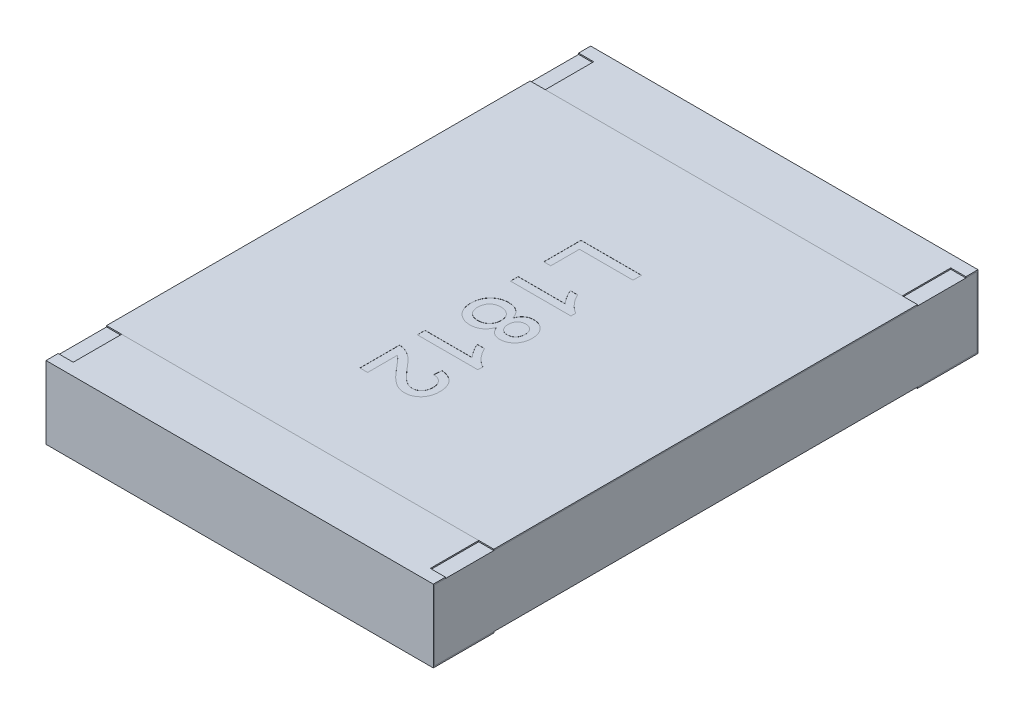
from build123d import *

# Parameters (mm, degrees)
BOSS_EXTRUDE2_DEPTH   = 1.6
BOSS_EXTRUDE2_2_DEPTH = 1.6
BOSS_EXTRUDE3_START   = -1.6
SKETCH5_W             = 4.48
SKETCH5_H             = 0.58
BOSS_EXTRUDE3_DEPTH   = 3.2
SKETCH6_W             = 0.125
SKETCH6_H             = 0.4
CUT_EXTRUDE1_DEPTH    = 0.01
SKETCH7_W             = 3.2
SKETCH7_H             = 3.5
BOSS_EXTRUDE4_DEPTH   = 0.01
TEXT1812_DEPTH        = 0.001


with BuildPart() as part:
    # Sketch4 → Boss-Extrude2 (new body, symmetric)
    with BuildSketch(Plane(origin=(0, 0, 0), x_dir=(0, 0, -1), z_dir=(1, 0, 0))):
        Polygon((-2.25, 0.3), (-2.25, -0.3), (-1.75, -0.3), (-1.75, -0.29), (-2.24, -0.29), (-2.24, 0.29), (-1.75, 0.29), (-1.75, 0.3), align=None)
    extrude(amount=BOSS_EXTRUDE2_DEPTH, both=True)


with BuildPart() as body_2:
    # Sketch4 → Boss-Extrude2 2 (new body, symmetric)
    with BuildSketch(Plane(origin=(0, 0, 0), x_dir=(0, 0, -1), z_dir=(1, 0, 0))):
        Polygon((1.75, 0.3), (2.25, 0.3), (2.25, -0.3), (1.75, -0.3), (1.75, -0.29), (2.24, -0.29), (2.24, 0.29), (1.75, 0.29), align=None)
    extrude(amount=BOSS_EXTRUDE2_2_DEPTH, both=True)


with BuildPart() as body_3:
    # Sketch5 → Boss-Extrude3 (new body)
    with BuildSketch(Plane(origin=(0, 0, 0), x_dir=(0, 0, -1), z_dir=(1, 0, 0)).offset(BOSS_EXTRUDE3_START)):
        Rectangle(SKETCH5_W, SKETCH5_H)
    extrude(amount=BOSS_EXTRUDE3_DEPTH)


with BuildPart() as cut_extrude1_tool:
    # Sketch6 → Cut-Extrude1 (new body)
    with BuildSketch(Plane(origin=(0, 0.3, 0), x_dir=(1, 0, 0), z_dir=(0, 1, 0))):
        with Locations((-1.5375, 1.95)):
            Rectangle(SKETCH6_W, SKETCH6_H)
        with Locations((1.5375, 1.95)):
            Rectangle(SKETCH6_W, SKETCH6_H)
        with Locations((1.5375, -1.95)):
            Rectangle(SKETCH6_W, SKETCH6_H)
        with Locations((-1.5375, -1.95)):
            Rectangle(SKETCH6_W, SKETCH6_H)
    extrude(amount=-CUT_EXTRUDE1_DEPTH)


with BuildPart() as part_1:
    add(part.part)

    # Cut-Extrude1: cut by cut_extrude1_tool
    add(cut_extrude1_tool.part, mode=Mode.SUBTRACT)


with BuildPart() as body_2_1:
    add(body_2.part)

    # Cut-Extrude1: cut by cut_extrude1_tool
    add(cut_extrude1_tool.part, mode=Mode.SUBTRACT)


with BuildPart() as body_4:
    # Sketch7 → Boss-Extrude4 (new body)
    with BuildSketch(Plane(origin=(0, 0.29, 0), x_dir=(1, 0, 0), z_dir=(0, 1, 0))):
        Rectangle(SKETCH7_W, SKETCH7_H)
    extrude(amount=BOSS_EXTRUDE4_DEPTH)

    # Sketch14 → TEXT1812 (cut)
    with BuildSketch(Plane(origin=(0, 0.3, 0), x_dir=(1, 0, 0), z_dir=(0, 1, 0))):
        Polygon((-0.25, 0.820138052), (0.25, 0.820138052), (0.25, 0.749625231), (-0.192307692, 0.749625231), (-0.192307692, 0.512445744), (-0.25, 0.512445744), align=None)
        with BuildLine():
            Line((-0.25, 0.236804718), (-0.25, 0.300907282))
            Line((-0.25, 0.300907282), (0.139623397, 0.300907282))
            add(Edge.make_bspline(
                [(0.139623397, 0.300907282), (0.136064182, 0.304598525), (0.128666742, 0.312270369), (0.118190939, 0.32523447), (0.107619408, 0.339700891), (0.097315673, 0.355429648), (0.08780582, 0.371586212), (0.079128194, 0.387152151), (0.071822591, 0.401910054), (0.067824115, 0.411628505), (0.065905449, 0.416291898)],
                knots=[0, 0, 0, 0, 1.5377e-05, 3.1959e-05, 4.9949e-05, 6.9117e-05, 8.8339e-05, 0.000106181, 0.000122576, 0.0001377, 0.0001377, 0.0001377, 0.0001377], degree=3))
            Line((0.065905449, 0.416291898), (0.125, 0.416291898))
            add(Edge.make_bspline(
                [(0.125, 0.416291898), (0.129125269, 0.408281697), (0.137255931, 0.392494067), (0.151298701, 0.370189558), (0.166521642, 0.3493659), (0.182921383, 0.330367807), (0.199684862, 0.313337227), (0.216599871, 0.29898531), (0.233046379, 0.286976539), (0.244515995, 0.280951511), (0.25, 0.278070744)],
                knots=[0, 0, 0, 0, 2.702e-05, 5.3254e-05, 7.8977e-05, 0.000104333, 0.000128484, 0.000150581, 0.000170841, 0.000189403, 0.000189403, 0.000189403, 0.000189403], degree=3))
            Line((0.25, 0.278070744), (0.25, 0.236804718))
            Line((0.25, 0.236804718), (-0.25, 0.236804718))
        make_face()
        with BuildLine():
            add(Edge.make_bspline(
                [(0.024238782, -0.018403615), (0.02539818, -0.015281088), (0.027670824, -0.009160331), (0.031729797, -0.000465484), (0.035977971, 0.007684965), (0.040722444, 0.015141883), (0.045841435, 0.02194777), (0.05125653, 0.028215415), (0.057051297, 0.033819199), (0.065251162, 0.040403963), (0.076469857, 0.047168124), (0.091129194, 0.053208557), (0.107150389, 0.056621476), (0.118206708, 0.057080991), (0.123898237, 0.057317539)],
                knots=[0, 0, 0, 0, 9.988e-06, 1.9579e-05, 2.8765e-05, 3.7545e-05, 4.6059e-05, 5.4294e-05, 6.2369e-05, 7.0206e-05, 8.5803e-05, 0.000101483, 0.000117572, 0.000134642, 0.000134642, 0.000134642, 0.000134642], degree=3))
            add(Edge.make_bspline(
                [(0.123898237, 0.057317539), (0.128278386, 0.057207296), (0.136876757, 0.056990886), (0.149495643, 0.055128788), (0.161579073, 0.052127737), (0.17314744, 0.047929631), (0.184113889, 0.042438802), (0.194640222, 0.035914222), (0.204558084, 0.028059088), (0.213797595, 0.019055628), (0.22236411, 0.009184216), (0.229759149, -0.001650872), (0.236018114, -0.013274409), (0.241127177, -0.025663435), (0.245166426, -0.038834398), (0.247909652, -0.052833921), (0.249656619, -0.067604982), (0.249883757, -0.077726769), (0.25, -0.08290682)],
                knots=[0, 0, 0, 0, 1.3135e-05, 2.5784e-05, 3.8173e-05, 5.0436e-05, 6.2619e-05, 7.4903e-05, 8.7527e-05, 0.00010049, 0.000113559, 0.000126672, 0.000139758, 0.000153094, 0.000166813, 0.000181015, 0.000195837, 0.000211373, 0.000211373, 0.000211373, 0.000211373], degree=3))
            add(Edge.make_bspline(
                [(0.25, -0.08290682), (0.249882531, -0.088119853), (0.249653714, -0.098274252), (0.247930845, -0.11312416), (0.245043208, -0.127210704), (0.240946379, -0.140525591), (0.235708336, -0.153089813), (0.229270093, -0.164820809), (0.221737839, -0.175839344), (0.213021747, -0.185863787), (0.203558906, -0.194984836), (0.193421, -0.202887363), (0.18284459, -0.209665109), (0.171765423, -0.215265897), (0.160057336, -0.219409382), (0.147940915, -0.222567647), (0.135272194, -0.224399587), (0.126675148, -0.224620968), (0.122295673, -0.224733743)],
                knots=[0, 0, 0, 0, 1.5637e-05, 3.0458e-05, 4.4778e-05, 5.8718e-05, 7.2186e-05, 8.5543e-05, 9.8796e-05, 0.000112147, 0.000125324, 0.000138167, 0.000150642, 0.00016296, 0.000175317, 0.000187828, 0.000200477, 0.000213612, 0.000213612, 0.000213612, 0.000213612], degree=3))
            add(Edge.make_bspline(
                [(0.122295673, -0.224733743), (0.116799676, -0.22454979), (0.10602306, -0.224189091), (0.090480034, -0.220539131), (0.076018484, -0.214801225), (0.062720931, -0.206703486), (0.050803482, -0.196122782), (0.040306374, -0.18318584), (0.031199936, -0.167895992), (0.026621629, -0.156530493), (0.024238782, -0.150615153)],
                knots=[0, 0, 0, 0, 1.6463e-05, 3.2281e-05, 4.7607e-05, 6.2981e-05, 7.8735e-05, 9.5177e-05, 0.000112783, 0.000131893, 0.000131893, 0.000131893, 0.000131893], degree=3))
            add(Edge.make_bspline(
                [(0.024238782, -0.150615153), (0.022972264, -0.15434827), (0.020490437, -0.161663558), (0.015654785, -0.171998845), (0.010491973, -0.181728536), (0.004755578, -0.19084414), (-0.001623653, -0.199214696), (-0.008616028, -0.206897991), (-0.016120459, -0.213941507), (-0.024261073, -0.220236187), (-0.032853908, -0.225862337), (-0.041930308, -0.230661063), (-0.051322704, -0.234796875), (-0.061196276, -0.238091248), (-0.071409343, -0.240847143), (-0.082118687, -0.242577705), (-0.093157345, -0.243725752), (-0.100658015, -0.243884098), (-0.104467147, -0.243964512)],
                knots=[0, 0, 0, 0, 1.1818e-05, 2.3157e-05, 3.4181e-05, 4.4851e-05, 5.5428e-05, 6.571e-05, 7.5985e-05, 8.6264e-05, 9.6542e-05, 0.000106759, 0.000117031, 0.000127293, 0.000137958, 0.000148727, 0.0001598, 0.000171225, 0.000171225, 0.000171225, 0.000171225], degree=3))
            add(Edge.make_bspline(
                [(-0.104467147, -0.243964512), (-0.109716763, -0.243837132), (-0.120058905, -0.243586184), (-0.135239829, -0.241380953), (-0.149823668, -0.238045088), (-0.163746516, -0.233178311), (-0.177026708, -0.226971864), (-0.189596023, -0.219269027), (-0.201582432, -0.210303597), (-0.212864831, -0.200075975), (-0.222998595, -0.188571212), (-0.232020834, -0.17621777), (-0.239541591, -0.16288028), (-0.245775203, -0.148730445), (-0.25060455, -0.133692382), (-0.253986549, -0.117787644), (-0.256000272, -0.101020908), (-0.256271764, -0.089556358), (-0.256410256, -0.083708102)],
                knots=[0, 0, 0, 0, 1.5741e-05, 3.1011e-05, 4.5928e-05, 6.0562e-05, 7.5169e-05, 8.9822e-05, 0.000104705, 0.00012002, 0.000135416, 0.000150623, 0.000165829, 0.000181256, 0.000196936, 0.000213123, 0.000229969, 0.000247512, 0.000247512, 0.000247512, 0.000247512], degree=3))
            add(Edge.make_bspline(
                [(-0.256410256, -0.083708102), (-0.256268784, -0.077860427), (-0.255991451, -0.066397015), (-0.254018827, -0.049615019), (-0.250483765, -0.033732826), (-0.24564863, -0.01871507), (-0.239586942, -0.004478045), (-0.23188486, 0.008759823), (-0.22294704, 0.02119123), (-0.212624421, 0.032529782), (-0.201347774, 0.042812622), (-0.189308416, 0.051894921), (-0.176534929, 0.059518571), (-0.163096374, 0.065813945), (-0.148943574, 0.070604959), (-0.134138206, 0.073969271), (-0.118689254, 0.076178202), (-0.108147498, 0.076423201), (-0.102764423, 0.076548308)],
                knots=[0, 0, 0, 0, 1.7542e-05, 3.4388e-05, 5.0597e-05, 6.6276e-05, 8.1664e-05, 9.692e-05, 0.000112127, 0.000127515, 0.000142829, 0.000157853, 0.000172678, 0.000187375, 0.000202294, 0.000217406, 0.000232874, 0.000249015, 0.000249015, 0.000249015, 0.000249015], degree=3))
            add(Edge.make_bspline(
                [(-0.102764423, 0.076548308), (-0.098756291, 0.076461416), (-0.090891642, 0.076290919), (-0.079356793, 0.075247857), (-0.068361168, 0.073173738), (-0.057847876, 0.070487423), (-0.047749211, 0.067125146), (-0.03826149, 0.062784714), (-0.029246667, 0.057730039), (-0.020751206, 0.051949572), (-0.012849932, 0.045402835), (-0.005462304, 0.038306998), (0.001111121, 0.030415976), (0.007217111, 0.022030101), (0.012370618, 0.012776387), (0.017102053, 0.003009595), (0.021136528, -0.007441155), (0.023194341, -0.014712865), (0.024238782, -0.018403615)],
                knots=[0, 0, 0, 0, 1.2026e-05, 2.3597e-05, 3.4697e-05, 4.5556e-05, 5.6135e-05, 6.6579e-05, 7.6804e-05, 8.7111e-05, 9.7357e-05, 0.000107557, 0.000117791, 0.00012813, 0.000138628, 0.000149514, 0.000160675, 0.000172178, 0.000172178, 0.000172178, 0.000172178], degree=3))
        make_face()
        with BuildLine():
            add(Edge.make_bspline(
                [(0.123597756, -0.006785025), (0.120991462, -0.0068427), (0.115896151, -0.006955456), (0.108439177, -0.007837621), (0.101377018, -0.009481524), (0.094654968, -0.011655877), (0.088296098, -0.014507799), (0.082239417, -0.017885961), (0.07663087, -0.022036111), (0.071437279, -0.02673761), (0.066668381, -0.031954448), (0.062556899, -0.037820128), (0.059025979, -0.044223923), (0.056288833, -0.051225851), (0.053861642, -0.058646941), (0.05250548, -0.066745793), (0.051402828, -0.075331297), (0.05132298, -0.081266687), (0.051282051, -0.084309064)],
                knots=[0, 0, 0, 0, 7.818e-06, 1.5285e-05, 2.2477e-05, 2.954e-05, 3.6445e-05, 4.3353e-05, 5.0304e-05, 5.7325e-05, 6.4345e-05, 7.146e-05, 7.8766e-05, 8.6224e-05, 9.3986e-05, 0.000102138, 0.00011081, 0.00011993, 0.00011993, 0.00011993, 0.00011993], degree=3))
            add(Edge.make_bspline(
                [(0.051282051, -0.084309064), (0.051324337, -0.087284354), (0.051406793, -0.093086006), (0.052489104, -0.101477167), (0.053924062, -0.109411295), (0.05614596, -0.116780159), (0.05889885, -0.123681995), (0.06252784, -0.129897263), (0.066452675, -0.135795881), (0.072742354, -0.142613787), (0.081592622, -0.149835113), (0.093575839, -0.156123412), (0.106731646, -0.160026), (0.115891397, -0.160425911), (0.120592949, -0.160631179)],
                knots=[0, 0, 0, 0, 8.919e-06, 1.7392e-05, 2.5348e-05, 3.308e-05, 4.0446e-05, 4.7577e-05, 5.4634e-05, 6.1654e-05, 7.5326e-05, 8.8677e-05, 0.000102023, 0.000116097, 0.000116097, 0.000116097, 0.000116097], degree=3))
            add(Edge.make_bspline(
                [(0.120592949, -0.160631179), (0.125459209, -0.160384425), (0.134981221, -0.159901592), (0.148650499, -0.156001968), (0.161030782, -0.149436608), (0.170071927, -0.141936595), (0.176621705, -0.134995096), (0.180791077, -0.12905629), (0.184339581, -0.122672051), (0.187237413, -0.115818082), (0.189574544, -0.10848447), (0.191107815, -0.100651349), (0.192183151, -0.092351636), (0.192265305, -0.086649904), (0.192307692, -0.083708102)],
                knots=[0, 0, 0, 0, 1.4581e-05, 2.8532e-05, 4.2242e-05, 5.6337e-05, 6.3567e-05, 7.082e-05, 7.8039e-05, 8.5443e-05, 9.3109e-05, 0.000101085, 0.000109358, 0.000118178, 0.000118178, 0.000118178, 0.000118178], degree=3))
            add(Edge.make_bspline(
                [(0.192307692, -0.083708102), (0.192266666, -0.08076598), (0.192186687, -0.075030456), (0.191079222, -0.066676526), (0.189687591, -0.058769515), (0.187456834, -0.051380391), (0.184533253, -0.044546864), (0.181018489, -0.038196355), (0.176892408, -0.032345598), (0.170652349, -0.025355677), (0.161895936, -0.017936378), (0.150029615, -0.01150081), (0.13713766, -0.007508302), (0.12816696, -0.007029104), (0.123597756, -0.006785025)],
                knots=[0, 0, 0, 0, 8.819e-06, 1.7193e-05, 2.5247e-05, 3.2883e-05, 4.0288e-05, 4.7506e-05, 5.462e-05, 6.1715e-05, 7.5578e-05, 8.88e-05, 0.000101982, 0.000115666, 0.000115666, 0.000115666, 0.000115666], degree=3))
        make_face(mode=Mode.SUBTRACT)
        with BuildLine():
            add(Edge.make_bspline(
                [(-0.1015625, 0.012445744), (-0.105675937, 0.012335584), (-0.113913647, 0.012114975), (-0.126143608, 0.010157317), (-0.138176392, 0.006889605), (-0.149918479, 0.002498368), (-0.161048518, -0.003434237), (-0.170904356, -0.011371511), (-0.179338866, -0.021225417), (-0.1862755, -0.032650539), (-0.191829654, -0.045018672), (-0.195726919, -0.057887136), (-0.198263034, -0.070954849), (-0.198566293, -0.07979038), (-0.198717949, -0.084208903)],
                knots=[0, 0, 0, 0, 1.2334e-05, 2.4701e-05, 3.7044e-05, 4.9693e-05, 6.2243e-05, 7.471e-05, 8.7421e-05, 0.000100958, 0.000114677, 0.000127983, 0.000141224, 0.00015447, 0.00015447, 0.00015447, 0.00015447], degree=3))
            add(Edge.make_bspline(
                [(-0.198717949, -0.084208903), (-0.198656227, -0.087852609), (-0.198536319, -0.094931289), (-0.197166117, -0.105249788), (-0.195087072, -0.114972149), (-0.192236359, -0.124142905), (-0.188336404, -0.132627106), (-0.183778167, -0.140562796), (-0.178269329, -0.147869228), (-0.171981829, -0.154542736), (-0.165028627, -0.160521334), (-0.157520547, -0.165625993), (-0.149712731, -0.170134481), (-0.141294279, -0.173590018), (-0.132494834, -0.176423087), (-0.123234593, -0.178404933), (-0.113548875, -0.179646981), (-0.106941658, -0.179789254), (-0.103565705, -0.179861948)],
                knots=[0, 0, 0, 0, 1.0925e-05, 2.1224e-05, 3.1164e-05, 4.0731e-05, 4.9965e-05, 5.9121e-05, 6.8136e-05, 7.7347e-05, 8.6581e-05, 9.5583e-05, 0.000104553, 0.000113575, 0.000122825, 0.000132255, 0.000141945, 0.000152069, 0.000152069, 0.000152069, 0.000152069], degree=3))
            add(Edge.make_bspline(
                [(-0.103565705, -0.179861948), (-0.100123487, -0.179786906), (-0.093384171, -0.179639985), (-0.083485869, -0.178429083), (-0.074062616, -0.176333166), (-0.065105205, -0.173374094), (-0.05652785, -0.169819465), (-0.048457959, -0.165281241), (-0.040966071, -0.159791276), (-0.03384257, -0.153752467), (-0.027392394, -0.146923736), (-0.021830619, -0.139381316), (-0.016918505, -0.131365833), (-0.01315053, -0.122634381), (-0.010132287, -0.113379439), (-0.007939188, -0.103557009), (-0.006598604, -0.093127049), (-0.006474251, -0.085982573), (-0.006410256, -0.082305859)],
                knots=[0, 0, 0, 0, 1.0324e-05, 2.0213e-05, 2.986e-05, 3.9236e-05, 4.8482e-05, 5.7675e-05, 6.6932e-05, 7.6307e-05, 8.566e-05, 9.5035e-05, 0.00010438, 0.000113797, 0.000123489, 0.000133549, 0.000143948, 0.000154973, 0.000154973, 0.000154973, 0.000154973], degree=3))
            add(Edge.make_bspline(
                [(-0.006410256, -0.082305859), (-0.006474999, -0.078729038), (-0.006601914, -0.071717357), (-0.007948541, -0.061530473), (-0.010024387, -0.051889794), (-0.013025373, -0.042894401), (-0.0168655, -0.034452302), (-0.021594505, -0.026640586), (-0.027127484, -0.019347092), (-0.033541909, -0.012789173), (-0.04056438, -0.006918269), (-0.047939309, -0.001642959), (-0.055878465, 0.0026585), (-0.064156655, 0.006319492), (-0.072957178, 0.008966906), (-0.08208906, 0.011000506), (-0.091680221, 0.012227818), (-0.098220261, 0.01237204), (-0.1015625, 0.012445744)],
                knots=[0, 0, 0, 0, 1.0725e-05, 2.1024e-05, 3.0769e-05, 4.0271e-05, 4.9414e-05, 5.8535e-05, 6.761e-05, 7.6818e-05, 8.5987e-05, 9.5046e-05, 0.000103967, 0.000113029, 0.000122153, 0.000131485, 0.000141076, 0.0001511, 0.0001511, 0.0001511, 0.0001511], degree=3))
        make_face(mode=Mode.SUBTRACT)
        with BuildLine():
            Line((-0.25, -0.532426051), (-0.25, -0.468323487))
            Line((-0.25, -0.468323487), (0.139623397, -0.468323487))
            add(Edge.make_bspline(
                [(0.139623397, -0.468323487), (0.136064182, -0.464632244), (0.128666742, -0.4569604), (0.118190939, -0.443996299), (0.107619408, -0.429529878), (0.097315673, -0.413801121), (0.08780582, -0.397644558), (0.079128194, -0.382078618), (0.071822591, -0.367320715), (0.067824115, -0.357602264), (0.065905449, -0.352938871)],
                knots=[0, 0, 0, 0, 1.5377e-05, 3.1959e-05, 4.9949e-05, 6.9117e-05, 8.8339e-05, 0.000106181, 0.000122576, 0.0001377, 0.0001377, 0.0001377, 0.0001377], degree=3))
            Line((0.065905449, -0.352938871), (0.125, -0.352938871))
            add(Edge.make_bspline(
                [(0.125, -0.352938871), (0.129125269, -0.360949072), (0.137255931, -0.376736703), (0.151298701, -0.399041211), (0.166521642, -0.419864869), (0.182921383, -0.438862962), (0.199684862, -0.455893542), (0.216599871, -0.47024546), (0.233046379, -0.482254231), (0.244515995, -0.488279258), (0.25, -0.491160025)],
                knots=[0, 0, 0, 0, 2.702e-05, 5.3254e-05, 7.8977e-05, 0.000104333, 0.000128484, 0.000150581, 0.000170841, 0.000189403, 0.000189403, 0.000189403, 0.000189403], degree=3))
            Line((0.25, -0.491160025), (0.25, -0.532426051))
            Line((0.25, -0.532426051), (-0.25, -0.532426051))
        make_face()
        with BuildLine():
            Line((-0.185897436, -1.006785025), (-0.25, -1.006785025))
            Line((-0.25, -1.006785025), (-0.25, -0.679861948))
            add(Edge.make_bspline(
                [(-0.25, -0.679861948), (-0.246190204, -0.679855255), (-0.238583383, -0.679841892), (-0.227333376, -0.681129089), (-0.21623261, -0.683145096), (-0.209114131, -0.685424596), (-0.205528846, -0.686572685)],
                knots=[0, 0, 0, 0, 1.142e-05, 2.2802e-05, 3.392e-05, 4.5202e-05, 4.5202e-05, 4.5202e-05, 4.5202e-05], degree=3))
            add(Edge.make_bspline(
                [(-0.205528846, -0.686572685), (-0.199672194, -0.688696046), (-0.187747085, -0.693019559), (-0.170501435, -0.701745549), (-0.153461868, -0.712179782), (-0.139489569, -0.72216557), (-0.128408004, -0.731362493), (-0.11963342, -0.738946588), (-0.110764129, -0.747489919), (-0.101641984, -0.756836742), (-0.092266458, -0.766930336), (-0.082593861, -0.777770307), (-0.07280804, -0.789488773), (-0.066321448, -0.797669318), (-0.063000801, -0.801857141)],
                knots=[0, 0, 0, 0, 1.8675e-05, 3.8026e-05, 5.7849e-05, 7.8586e-05, 8.9474e-05, 0.000101045, 0.000113371, 0.000126404, 0.000140223, 0.000154696, 0.000169983, 0.000186016, 0.000186016, 0.000186016, 0.000186016], degree=3))
            add(Edge.make_bspline(
                [(-0.063000801, -0.801857141), (-0.057585784, -0.808290694), (-0.047158825, -0.820678908), (-0.031686185, -0.838173008), (-0.017318962, -0.85415102), (-0.003805341, -0.868358514), (0.008723604, -0.880911691), (0.020239487, -0.891840027), (0.03070637, -0.901237552), (0.040503108, -0.908989541), (0.049753955, -0.915530132), (0.058777584, -0.921072705), (0.06773162, -0.925691704), (0.076587728, -0.929538712), (0.085383783, -0.932581369), (0.094145409, -0.934655372), (0.102785672, -0.93606189), (0.108534999, -0.936202613), (0.111378205, -0.936272205)],
                knots=[0, 0, 0, 0, 2.5226e-05, 4.8575e-05, 7.0061e-05, 8.9685e-05, 0.000107391, 0.000123262, 0.00013731, 0.000149574, 0.000160717, 0.000171282, 0.000181316, 0.000190917, 0.000200229, 0.000209193, 0.000217905, 0.000226428, 0.000226428, 0.000226428, 0.000226428], degree=3))
            add(Edge.make_bspline(
                [(0.111378205, -0.936272205), (0.114188238, -0.936202605), (0.119701369, -0.936066053), (0.127769802, -0.93477046), (0.135539896, -0.93296689), (0.14287177, -0.930051066), (0.149982559, -0.92658036), (0.156647535, -0.922128331), (0.163032944, -0.916978292), (0.168969907, -0.911081764), (0.17454131, -0.904642015), (0.179166687, -0.897444095), (0.183368098, -0.889944906), (0.186646742, -0.881896597), (0.189173495, -0.873370848), (0.190933763, -0.864381334), (0.192071797, -0.854904052), (0.192227868, -0.848435013), (0.192307692, -0.845126371)],
                knots=[0, 0, 0, 0, 8.423e-06, 1.6525e-05, 2.4469e-05, 3.23e-05, 4.0139e-05, 4.8167e-05, 5.6286e-05, 6.4714e-05, 7.3243e-05, 8.1771e-05, 9.0332e-05, 9.9e-05, 0.000107778, 0.000116971, 0.00012645, 0.000136374, 0.000136374, 0.000136374, 0.000136374], degree=3))
            add(Edge.make_bspline(
                [(0.192307692, -0.845126371), (0.192227732, -0.841650932), (0.192071243, -0.834849241), (0.190936175, -0.824905916), (0.189191722, -0.815470492), (0.186569692, -0.806576624), (0.183136978, -0.798242097), (0.179045534, -0.790407826), (0.174196706, -0.783103767), (0.168565002, -0.776446806), (0.162430447, -0.770280388), (0.155494268, -0.76507112), (0.148121475, -0.760517507), (0.140077995, -0.756925285), (0.131540513, -0.753995715), (0.122382293, -0.751881138), (0.11264261, -0.750725427), (0.105972365, -0.750493351), (0.102564103, -0.750374769)],
                knots=[0, 0, 0, 0, 1.0424e-05, 2.0401e-05, 2.9987e-05, 3.9178e-05, 4.8162e-05, 5.6988e-05, 6.5655e-05, 7.4401e-05, 8.3113e-05, 9.1687e-05, 0.000100362, 0.000109057, 0.000118053, 0.000127407, 0.000137196, 0.000147425, 0.000147425, 0.000147425, 0.000147425], degree=3))
            Line((0.102564103, -0.750374769), (0.108974359, -0.686272205))
            add(Edge.make_bspline(
                [(0.108974359, -0.686272205), (0.114561103, -0.686927996), (0.125429633, -0.688203782), (0.141170053, -0.691382874), (0.15581619, -0.695841323), (0.169558239, -0.701192174), (0.182228095, -0.707851111), (0.193871977, -0.715570873), (0.20454309, -0.724345443), (0.213993267, -0.734327621), (0.222618938, -0.745135341), (0.229876147, -0.757036708), (0.236164414, -0.769755625), (0.241249058, -0.783382616), (0.245145041, -0.797912332), (0.247930691, -0.813322144), (0.249649875, -0.829629495), (0.249881626, -0.840815201), (0.25, -0.846528615)],
                knots=[0, 0, 0, 0, 1.6871e-05, 3.2822e-05, 4.8095e-05, 6.2751e-05, 7.6998e-05, 9.0943e-05, 0.000104601, 0.000118344, 0.000132109, 0.000146007, 0.000160072, 0.00017462, 0.000189563, 0.000205142, 0.000221557, 0.000238695, 0.000238695, 0.000238695, 0.000238695], degree=3))
            add(Edge.make_bspline(
                [(0.25, -0.846528615), (0.24990096, -0.852310371), (0.249708029, -0.863573267), (0.247735103, -0.87998542), (0.244659885, -0.895469607), (0.240382222, -0.910087805), (0.234732773, -0.923762348), (0.227928529, -0.936540056), (0.219852523, -0.948380468), (0.210540088, -0.959122846), (0.200369372, -0.96881021), (0.189509921, -0.977287299), (0.178049555, -0.984414089), (0.166021375, -0.990308921), (0.153347568, -0.994822648), (0.140075652, -0.997963896), (0.126237909, -1.000108145), (0.116795268, -1.000284713), (0.111979167, -1.000374769)],
                knots=[0, 0, 0, 0, 1.7338e-05, 3.3775e-05, 4.9509e-05, 6.4657e-05, 7.9389e-05, 9.3818e-05, 0.000108014, 0.000122289, 0.000136388, 0.000150092, 0.000163543, 0.000176803, 0.000190204, 0.000203808, 0.000217675, 0.000232111, 0.000232111, 0.000232111, 0.000232111], degree=3))
            add(Edge.make_bspline(
                [(0.111979167, -1.000374769), (0.107030663, -1.00023958), (0.097122734, -0.999968903), (0.082332055, -0.997776777), (0.067657262, -0.994248118), (0.052981733, -0.989351835), (0.038292684, -0.98253776), (0.023237391, -0.974145686), (0.007927337, -0.963656733), (-0.005185376, -0.953709649), (-0.016100688, -0.944344209), (-0.025104319, -0.93604287), (-0.034707985, -0.926441073), (-0.045099702, -0.915794154), (-0.056125829, -0.903884046), (-0.067952516, -0.890927781), (-0.080329296, -0.876668026), (-0.088782578, -0.866767061), (-0.093149038, -0.861652814)],
                knots=[0, 0, 0, 0, 1.484e-05, 2.9713e-05, 4.4751e-05, 6.0081e-05, 7.6038e-05, 9.3257e-05, 0.000111731, 0.000131664, 0.000142604, 0.000154866, 0.000168394, 0.000183339, 0.000199497, 0.000217082, 0.000235964, 0.000256139, 0.000256139, 0.000256139, 0.000256139], degree=3))
            add(Edge.make_bspline(
                [(-0.093149038, -0.861652814), (-0.096714295, -0.857273318), (-0.103512691, -0.848922294), (-0.113369606, -0.837042294), (-0.122404327, -0.826398144), (-0.1303383, -0.816755085), (-0.137487823, -0.808439854), (-0.143708014, -0.801274102), (-0.149086369, -0.795328983), (-0.157337473, -0.786265952), (-0.169000351, -0.774699838), (-0.180421993, -0.766246257), (-0.185897436, -0.762193679)],
                knots=[0, 0, 0, 0, 1.6942e-05, 3.2305e-05, 4.6309e-05, 5.8826e-05, 6.9766e-05, 7.9207e-05, 8.7292e-05, 9.3814e-05, 0.000115985, 0.0001364, 0.0001364, 0.0001364, 0.0001364], degree=3))
            Line((-0.185897436, -0.762193679), (-0.185897436, -1.006785025))
        make_face()
    extrude(amount=-TEXT1812_DEPTH, mode=Mode.SUBTRACT)


solid = Compound([body_3.part, part_1.part, body_2_1.part, body_4.part])
